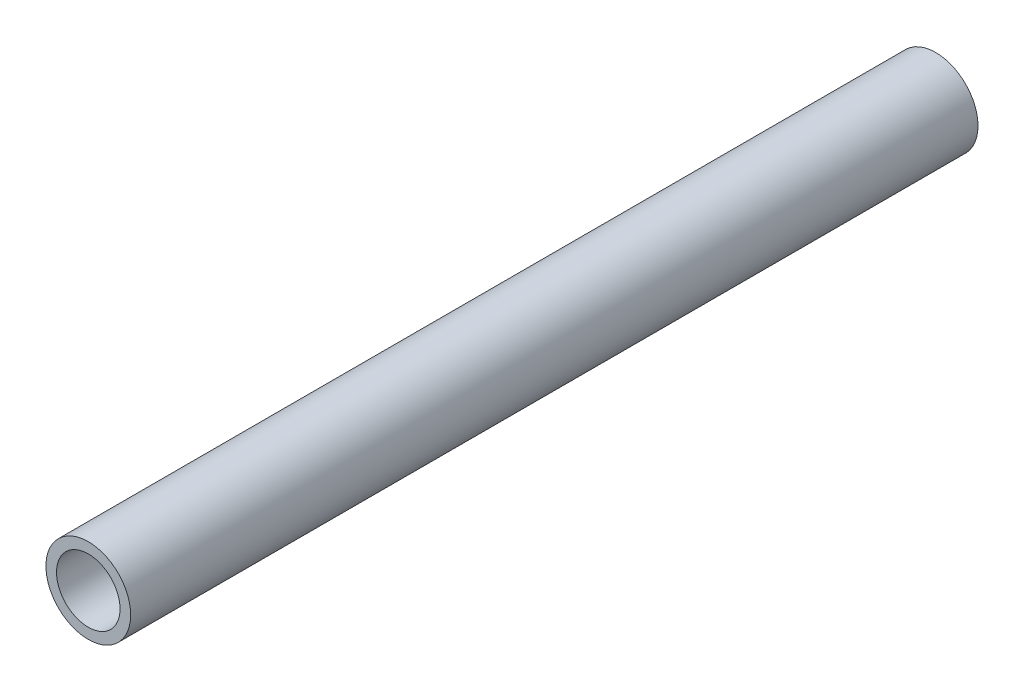
from build123d import *

# Parameters (mm, degrees)
CROQUIS1_R              = 4
CROQUIS1_R_2            = 3
SALIENTE_EXTRUIR1_DEPTH = 80


with BuildPart() as part:
    # Croquis1 → Saliente-Extruir1 (new body)
    with BuildSketch(Plane.XY):
        Circle(CROQUIS1_R)
        Circle(CROQUIS1_R_2, mode=Mode.SUBTRACT)
    extrude(amount=SALIENTE_EXTRUIR1_DEPTH)


solid = part.part
